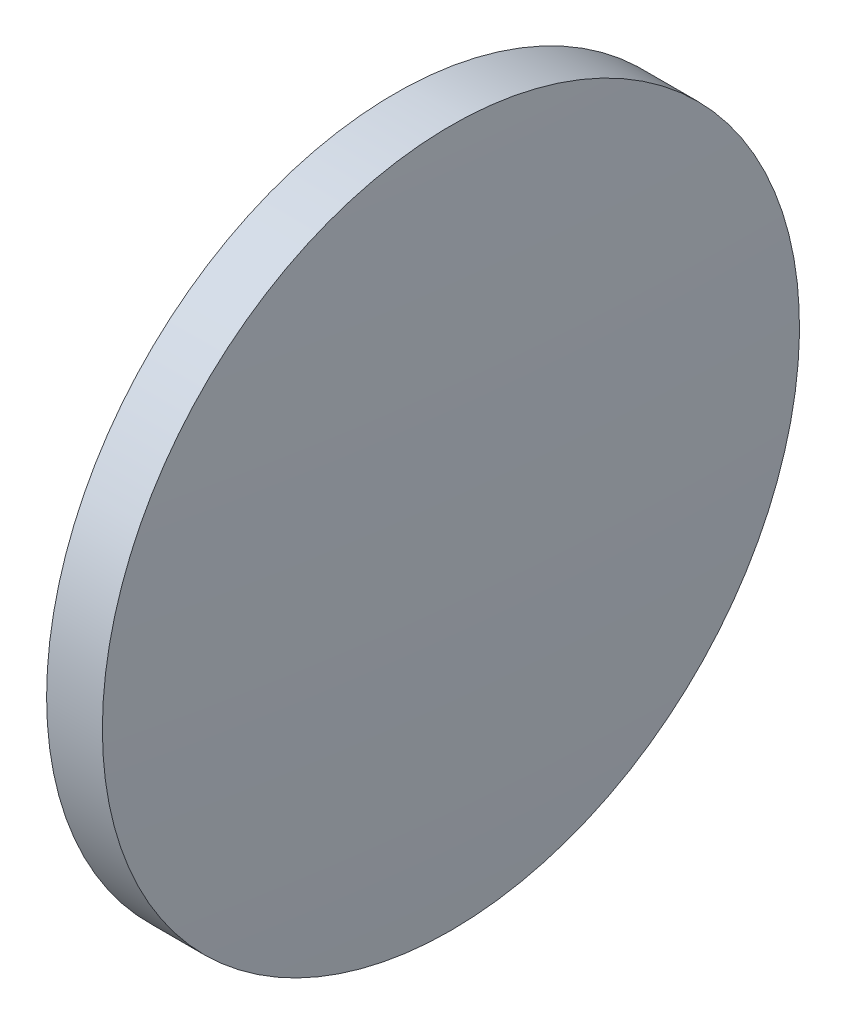
from build123d import *


with BuildPart() as part:
    # 草图1 → 旋转1 (revolve)
    with BuildSketch(Plane.XY, mode=Mode.PRIVATE) as revolve_1_sk:
        with BuildLine():
            Line((591.77431671, 81.37318733), (591.77431671, 93.87318733))
            Line((591.77431671, 93.87318733), (593.77431671, 93.87318733))
            ThreePointArc((593.77431671, 93.87318733), (593.999305913, 87.624987071), (594.07431671, 81.37318733))
            Line((594.07431671, 81.37318733), (591.77431671, 81.37318733))
        make_face()
    revolve(revolve_1_sk.sketch.rotate(Axis((589.408700808, 81.37318733, 0), (1, 0, 0)), 180), axis=Axis((589.408700808, 81.37318733, 0), (1, 0, 0)))  # turned: the seam where the file's is


solid = part.part
